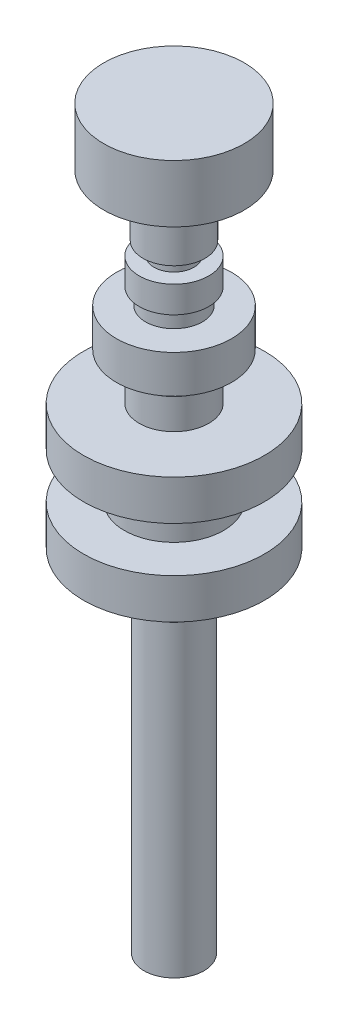
from build123d import *


with BuildPart() as part:
    # Sketch1 → Revolve2 (revolve)
    with BuildSketch(Plane.XY):
        Polygon((0, 0), (4.75, 0), (4.75, 49.8), (6.3, 49.8), (6.3, 55.5), (14.3, 55.5), (14.3, 61.85), (7.85, 61.85), (7.85, 69), (14.3, 69), (14.3, 75.35), (5.5, 75.35), (5.5, 80.15), (4.5, 80.15), (4.5, 82.75), (9.1, 82.75), (9.1, 88.75), (4.5, 88.75), (4.5, 91.35), (5.5, 91.35), (5.5, 95.55), (3.15, 95.55), (3.15, 97.65), (4.9, 97.65), (4.9, 107.35), (11.1, 107.35), (11.1, 116.45), (0, 116.45), align=None)
    revolve(axis=Axis((0, 0, 0), (0, 1, 0)))


solid = part.part
